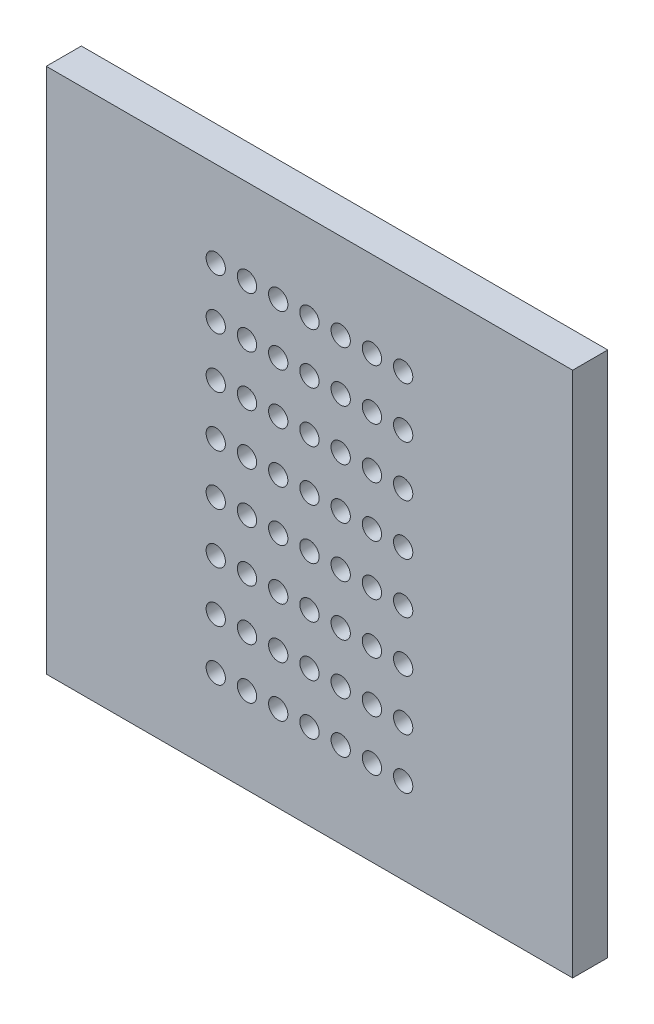
from build123d import *

# Parameters (mm, degrees)
ESQUISSE1_W            = 30
ESQUISSE1_H            = 30
BASE_PLATE_DEPTH       = 2
SKETCH_PERFORATIONS_R  = 0.55
CUT_PERFORATIONS_DEPTH = 10


with BuildPart() as part:
    # Esquisse1 → Base_Plate (new body)
    with BuildSketch(Plane.XY):
        Rectangle(ESQUISSE1_W, ESQUISSE1_H)
    extrude(amount=BASE_PLATE_DEPTH)

    # Sketch_Perforations → Cut_Perforations (cut)
    with BuildSketch(Plane.XY.offset(2)):
        with Locations((-5.34, -10.11)):
            Circle(SKETCH_PERFORATIONS_R)
        with Locations((-5.34, -7.22)):
            Circle(SKETCH_PERFORATIONS_R)
        with Locations((-5.34, -4.33)):
            Circle(SKETCH_PERFORATIONS_R)
        with Locations((-5.34, -1.44)):
            Circle(SKETCH_PERFORATIONS_R)
        with Locations((-5.34, 1.44)):
            Circle(SKETCH_PERFORATIONS_R)
        with Locations((-5.34, 4.33)):
            Circle(SKETCH_PERFORATIONS_R)
        with Locations((-5.34, 7.22)):
            Circle(SKETCH_PERFORATIONS_R)
        with Locations((-5.34, 10.11)):
            Circle(SKETCH_PERFORATIONS_R)
        with Locations((-3.56, -10.11)):
            Circle(SKETCH_PERFORATIONS_R)
        with Locations((-3.56, -7.22)):
            Circle(SKETCH_PERFORATIONS_R)
        with Locations((-3.56, -4.33)):
            Circle(SKETCH_PERFORATIONS_R)
        with Locations((-3.56, -1.44)):
            Circle(SKETCH_PERFORATIONS_R)
        with Locations((-3.56, 1.44)):
            Circle(SKETCH_PERFORATIONS_R)
        with Locations((-3.56, 4.33)):
            Circle(SKETCH_PERFORATIONS_R)
        with Locations((-3.56, 7.22)):
            Circle(SKETCH_PERFORATIONS_R)
        with Locations((-3.56, 10.11)):
            Circle(SKETCH_PERFORATIONS_R)
        with Locations((-1.78, -10.11)):
            Circle(SKETCH_PERFORATIONS_R)
        with Locations((-1.78, -7.22)):
            Circle(SKETCH_PERFORATIONS_R)
        with Locations((-1.78, -4.33)):
            Circle(SKETCH_PERFORATIONS_R)
        with Locations((-1.78, -1.44)):
            Circle(SKETCH_PERFORATIONS_R)
        with Locations((-1.78, 1.44)):
            Circle(SKETCH_PERFORATIONS_R)
        with Locations((-1.78, 4.33)):
            Circle(SKETCH_PERFORATIONS_R)
        with Locations((-1.78, 7.22)):
            Circle(SKETCH_PERFORATIONS_R)
        with Locations((-1.78, 10.11)):
            Circle(SKETCH_PERFORATIONS_R)
        with Locations((0, -10.11)):
            Circle(SKETCH_PERFORATIONS_R)
        with Locations((0, -7.22)):
            Circle(SKETCH_PERFORATIONS_R)
        with Locations((0, -4.33)):
            Circle(SKETCH_PERFORATIONS_R)
        with Locations((0, -1.44)):
            Circle(SKETCH_PERFORATIONS_R)
        with Locations((0, 1.44)):
            Circle(SKETCH_PERFORATIONS_R)
        with Locations((0, 4.33)):
            Circle(SKETCH_PERFORATIONS_R)
        with Locations((0, 7.22)):
            Circle(SKETCH_PERFORATIONS_R)
        with Locations((0, 10.11)):
            Circle(SKETCH_PERFORATIONS_R)
        with Locations((1.78, -10.11)):
            Circle(SKETCH_PERFORATIONS_R)
        with Locations((1.78, -7.22)):
            Circle(SKETCH_PERFORATIONS_R)
        with Locations((1.78, -4.33)):
            Circle(SKETCH_PERFORATIONS_R)
        with Locations((1.78, -1.44)):
            Circle(SKETCH_PERFORATIONS_R)
        with Locations((1.78, 1.44)):
            Circle(SKETCH_PERFORATIONS_R)
        with Locations((1.78, 4.33)):
            Circle(SKETCH_PERFORATIONS_R)
        with Locations((1.78, 7.22)):
            Circle(SKETCH_PERFORATIONS_R)
        with Locations((1.78, 10.11)):
            Circle(SKETCH_PERFORATIONS_R)
        with Locations((3.56, -10.11)):
            Circle(SKETCH_PERFORATIONS_R)
        with Locations((3.56, -7.22)):
            Circle(SKETCH_PERFORATIONS_R)
        with Locations((3.56, -4.33)):
            Circle(SKETCH_PERFORATIONS_R)
        with Locations((3.56, -1.44)):
            Circle(SKETCH_PERFORATIONS_R)
        with Locations((3.56, 1.44)):
            Circle(SKETCH_PERFORATIONS_R)
        with Locations((3.56, 4.33)):
            Circle(SKETCH_PERFORATIONS_R)
        with Locations((3.56, 7.22)):
            Circle(SKETCH_PERFORATIONS_R)
        with Locations((3.56, 10.11)):
            Circle(SKETCH_PERFORATIONS_R)
        with Locations((5.34, -10.11)):
            Circle(SKETCH_PERFORATIONS_R)
        with Locations((5.34, -7.22)):
            Circle(SKETCH_PERFORATIONS_R)
        with Locations((5.34, -4.33)):
            Circle(SKETCH_PERFORATIONS_R)
        with Locations((5.34, -1.44)):
            Circle(SKETCH_PERFORATIONS_R)
        with Locations((5.34, 1.44)):
            Circle(SKETCH_PERFORATIONS_R)
        with Locations((5.34, 4.33)):
            Circle(SKETCH_PERFORATIONS_R)
        with Locations((5.34, 7.22)):
            Circle(SKETCH_PERFORATIONS_R)
        with Locations((5.34, 10.11)):
            Circle(SKETCH_PERFORATIONS_R)
    extrude(amount=-CUT_PERFORATIONS_DEPTH, mode=Mode.SUBTRACT)


solid = part.part
